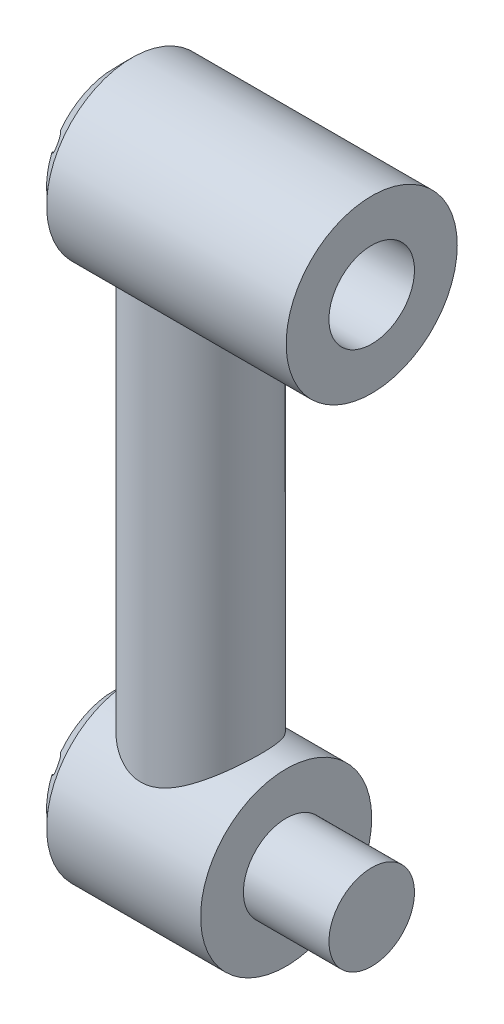
from build123d import *

# Parameters (mm, degrees)
SKETCH1_R           = 88.9
BOSS_EXTRUDE1_DEPTH = 317.5
SKETCH4_R           = 127
BOSS_EXTRUDE2_DEPTH = 127
SKETCH5_R           = 63.5
BOSS_EXTRUDE3_DEPTH = 127
SKETCH6_R           = 127
SKETCH6_R_2         = 63.5
BOSS_EXTRUDE4_DEPTH = 127
CHAMFER1_SIZE       = 25.4
SKETCH7_R           = 12.7
CUT_EXTRUDE1_DEPTH  = 25.4


with BuildPart() as part:
    # Sketch1 → Boss-Extrude1 (new body, symmetric)
    with BuildSketch(Plane(origin=(0, 0, 0), x_dir=(1, 0, 0), z_dir=(0, 1, 0))):
        Circle(SKETCH1_R)
    extrude(amount=BOSS_EXTRUDE1_DEPTH, both=True)

    # Sketch4 → Boss-Extrude2 (add, symmetric)
    with BuildSketch(Plane(origin=(0, 0, 0), x_dir=(0, 0, -1), z_dir=(1, 0, 0))):
        with Locations((0, 406.4)):
            Circle(SKETCH4_R)
        with Locations((0, -393.7)):
            Circle(SKETCH4_R)
    extrude(amount=BOSS_EXTRUDE2_DEPTH, both=True)

    # Sketch5 → Boss-Extrude3 (add)
    with BuildSketch(Plane(origin=(127, 0, 0), x_dir=(0, 0, -1), z_dir=(1, 0, 0))):
        with Locations((0, -393.7)):
            Circle(SKETCH5_R)
    extrude(amount=BOSS_EXTRUDE3_DEPTH)

    # Sketch6 → Boss-Extrude4 (add)
    with BuildSketch(Plane(origin=(127, 0, 0), x_dir=(0, 0, -1), z_dir=(1, 0, 0))):
        with Locations((0, 406.4)):
            Circle(SKETCH6_R)
        with Locations((0, 406.4)):
            Circle(SKETCH6_R_2, mode=Mode.SUBTRACT)
    extrude(amount=BOSS_EXTRUDE4_DEPTH)

    # Chamfer1
    chamfer1_edges = [part.edges().sort_by_distance(p)[0] for p in [
        (-127, -393.7, 127),
        (-127, 406.4, 127),
    ]]
    chamfer(chamfer1_edges, length=CHAMFER1_SIZE)

    # Sketch7 → Cut-Extrude1 (cut)
    with BuildSketch(Plane.ZY.offset(127)):
        with Locations((0, 508)):
            Circle(SKETCH7_R)
        with Locations((0, -292.1)):
            Circle(SKETCH7_R)
        with Locations((87.988181025, 457.2)):
            Circle(SKETCH7_R)
        with Locations((87.988181025, 355.6)):
            Circle(SKETCH7_R)
        with Locations((0, 304.8)):
            Circle(SKETCH7_R)
        with Locations((-87.988181024, 355.6)):
            Circle(SKETCH7_R)
        with Locations((-87.988181024, 457.2)):
            Circle(SKETCH7_R)
        with Locations((87.988181025, -342.9)):
            Circle(SKETCH7_R)
        with Locations((87.988181025, -444.5)):
            Circle(SKETCH7_R)
        with Locations((0, -495.3)):
            Circle(SKETCH7_R)
        with Locations((-87.988181024, -444.5)):
            Circle(SKETCH7_R)
        with Locations((-87.988181024, -342.9)):
            Circle(SKETCH7_R)
    extrude(amount=-CUT_EXTRUDE1_DEPTH, mode=Mode.SUBTRACT)


solid = part.part
